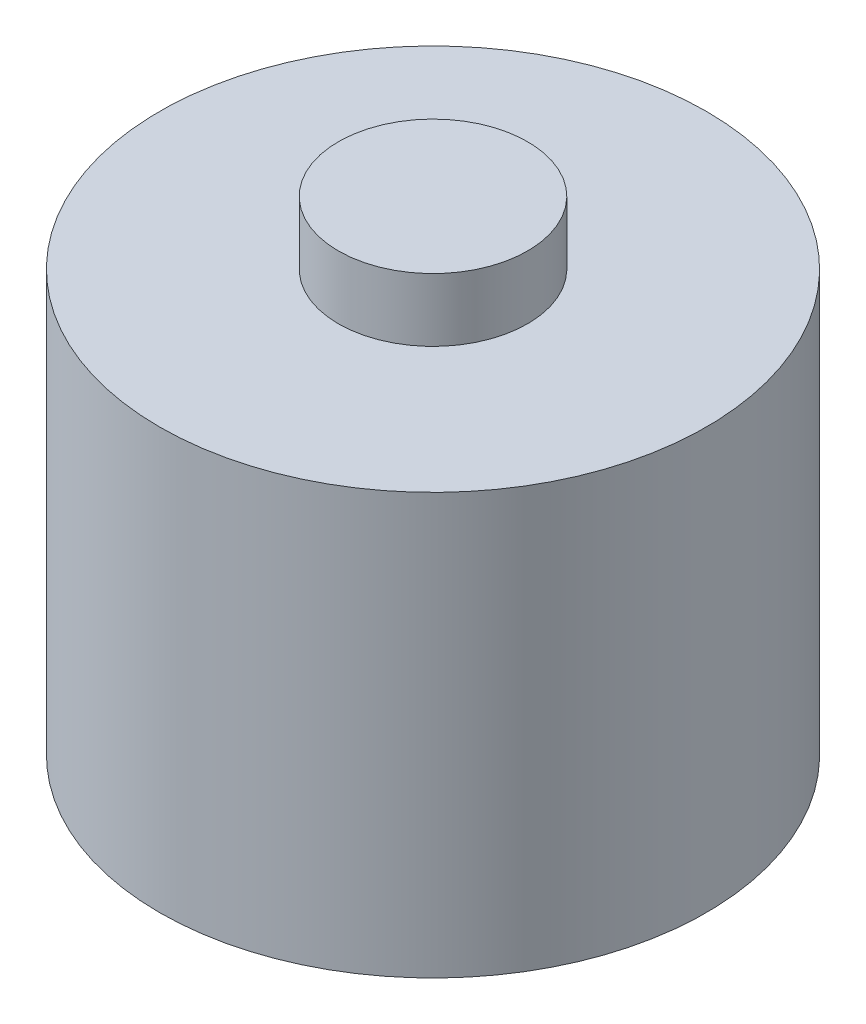
from build123d import *

# Parameters (mm, degrees)
SKETCH1_R           = 13
BOSS_EXTRUDE1_DEPTH = 20
SKETCH1_3_R         = 13
BOSS_EXTRUDE2_DEPTH = 20
SKETCH1_4_R         = 13
BOSS_EXTRUDE3_DEPTH = 20
SKETCH5_R           = 4.5
BOSS_EXTRUDE4_DEPTH = 3


with BuildPart() as part:
    # Sketch1 → Boss-Extrude1 (new body)
    with BuildSketch(Plane(origin=(0, 0, 0), x_dir=(1, 0, 0), z_dir=(0, 1, 0))):
        Circle(SKETCH1_R)
    extrude(amount=BOSS_EXTRUDE1_DEPTH)

    # Sketch1_3 → Boss-Extrude2 (add)
    with BuildSketch(Plane(origin=(0, 0, 0), x_dir=(1, 0, 0), z_dir=(0, 1, 0))):
        Circle(SKETCH1_3_R)
    extrude(amount=BOSS_EXTRUDE2_DEPTH)

    # Sketch1_4 → Boss-Extrude3 (add)
    with BuildSketch(Plane(origin=(0, 0, 0), x_dir=(1, 0, 0), z_dir=(0, 1, 0))):
        Circle(SKETCH1_4_R)
    extrude(amount=BOSS_EXTRUDE3_DEPTH)

    # Sketch5 → Boss-Extrude4 (add)
    with BuildSketch(Plane(origin=(0, 20, 0), x_dir=(1, 0, 0), z_dir=(0, 1, 0))):
        Circle(SKETCH5_R)
    extrude(amount=BOSS_EXTRUDE4_DEPTH)


solid = part.part
